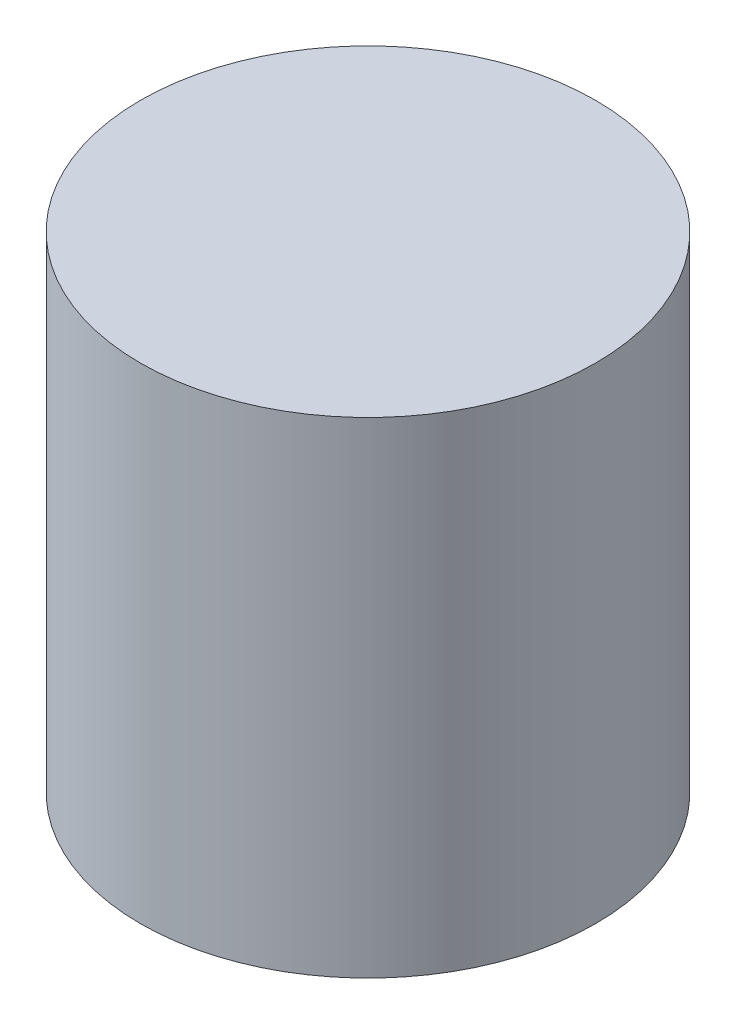
from build123d import *

# Parameters (mm, degrees)
SKETCH1_R           = 37.5
BOSS_EXTRUDE1_DEPTH = 80


with BuildPart() as part:
    # Sketch1 → Boss-Extrude1 (new body)
    with BuildSketch(Plane(origin=(0, 0, 0), x_dir=(1, 0, 0), z_dir=(0, 1, 0))):
        Circle(SKETCH1_R)
    extrude(amount=BOSS_EXTRUDE1_DEPTH)


solid = part.part
